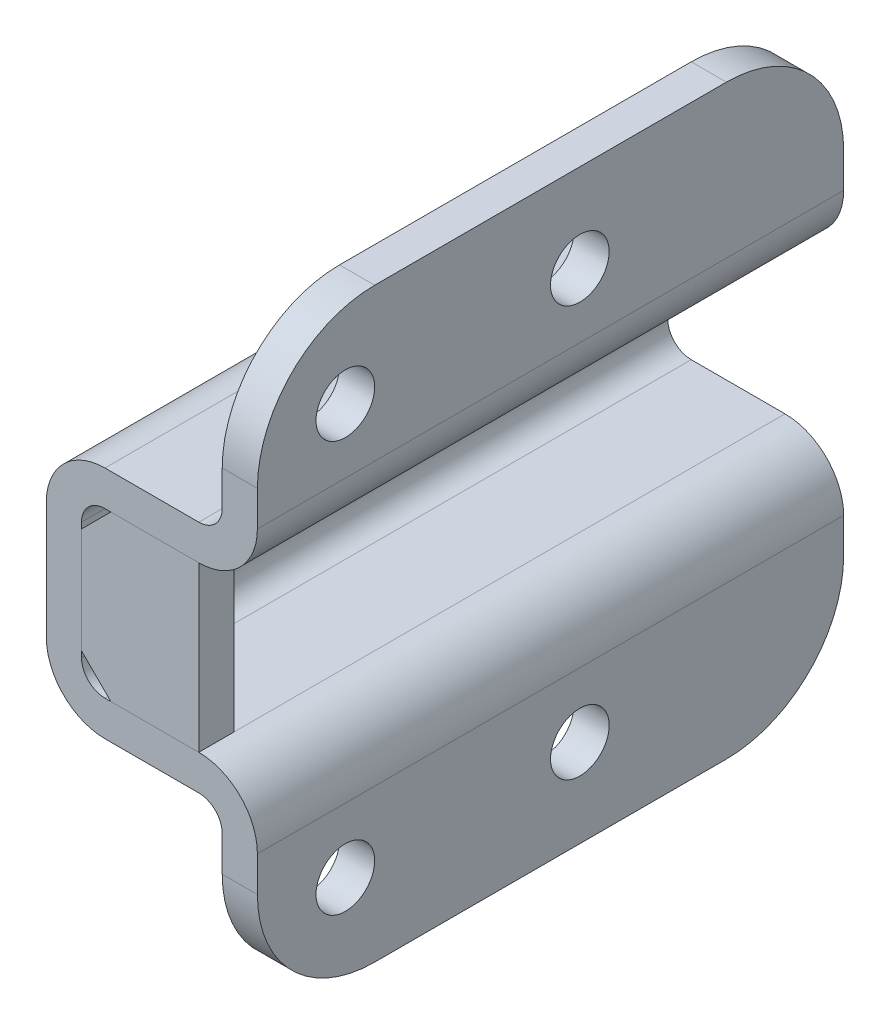
from build123d import *

# Parameters (mm, degrees)
EXTRUDE_1_DEPTH     = 100
CUT_EXTRUDE_1_REACH = 38
SKETCH_2_R          = 5
CUT_EXTRUDE_2_REACH = 8
SKETCH_3_R          = 5
EXTRUDE_2_DEPTH     = 6
FILLET_1_R          = 20


with BuildPart() as part:
    # 草图1 → 凸台-拉伸1 (new body)
    with BuildSketch(Plane.XY):
        with BuildLine():
            Line((0, 10), (0, 30))
            ThreePointArc((0, 30), (2.928932188, 37.071067812), (10, 40))
            Line((10, 40), (26, 40))
            ThreePointArc((26, 40), (28.828427125, 41.171572875), (30, 44))
            Line((30, 44), (30, 70))
            Line((30, 70), (36, 70))
            Line((36, 70), (36, 44))
            ThreePointArc((36, 44), (33.071067812, 36.928932188), (26, 34))
            Line((26, 34), (10, 34))
            ThreePointArc((10, 34), (7.171572875, 32.828427125), (6, 30))
            Line((6, 30), (6, 10))
            ThreePointArc((6, 10), (7.171572875, 7.171572875), (10, 6))
            Line((10, 6), (26, 6))
            ThreePointArc((26, 6), (33.071067812, 3.071067812), (36, -4))
            Line((36, -4), (36, -30))
            Line((36, -30), (30, -30))
            Line((30, -30), (30, -4))
            ThreePointArc((30, -4), (28.828427125, -1.171572875), (26, 0))
            Line((26, 0), (10, 0))
            ThreePointArc((10, 0), (2.928932188, 2.928932188), (0, 10))
        make_face()
    extrude(amount=EXTRUDE_1_DEPTH)

    # 草图2 → 切除-拉伸1 (cut, up to next)
    with BuildSketch(Plane.ZY, mode=Mode.PRIVATE) as cut_extrude_1_sk1:
        with Locations((20, 20)):
            Circle(SKETCH_2_R)
    cut_extrude_1_tool1 = extrude(cut_extrude_1_sk1.sketch, amount=-CUT_EXTRUDE_1_REACH, mode=Mode.PRIVATE) & part.part
    add(cut_extrude_1_tool1.solids().sort_by_distance((0, 20, 20))[0], mode=Mode.SUBTRACT)

    # 草图3 → 切除-拉伸2 (cut, up to next)
    with BuildSketch(Plane.ZY.offset(-30), mode=Mode.PRIVATE) as cut_extrude_2_sk1:
        with Locations((85, 55)):
            Circle(SKETCH_3_R)
    cut_extrude_2_tool1 = extrude(cut_extrude_2_sk1.sketch, amount=-CUT_EXTRUDE_2_REACH, mode=Mode.PRIVATE) & part.part
    add(cut_extrude_2_tool1.solids().sort_by_distance((30, 55, 85))[0], mode=Mode.SUBTRACT)
    # 草图3 → 切除-拉伸2 (cut, up to next)
    with BuildSketch(Plane.ZY.offset(-30), mode=Mode.PRIVATE) as cut_extrude_2_sk2:
        with Locations((45, 55)):
            Circle(SKETCH_3_R)
    cut_extrude_2_tool2 = extrude(cut_extrude_2_sk2.sketch, amount=-CUT_EXTRUDE_2_REACH, mode=Mode.PRIVATE) & part.part
    add(cut_extrude_2_tool2.solids().sort_by_distance((30, 55, 45))[0], mode=Mode.SUBTRACT)
    # 草图3 → 切除-拉伸2 (cut, up to next)
    with BuildSketch(Plane.ZY.offset(-30), mode=Mode.PRIVATE) as cut_extrude_2_sk3:
        with Locations((45, -15)):
            Circle(SKETCH_3_R)
    cut_extrude_2_tool3 = extrude(cut_extrude_2_sk3.sketch, amount=-CUT_EXTRUDE_2_REACH, mode=Mode.PRIVATE) & part.part
    add(cut_extrude_2_tool3.solids().sort_by_distance((30, -15, 45))[0], mode=Mode.SUBTRACT)
    # 草图3 → 切除-拉伸2 (cut, up to next)
    with BuildSketch(Plane.ZY.offset(-30), mode=Mode.PRIVATE) as cut_extrude_2_sk4:
        with Locations((85, -15)):
            Circle(SKETCH_3_R)
    cut_extrude_2_tool4 = extrude(cut_extrude_2_sk4.sketch, amount=-CUT_EXTRUDE_2_REACH, mode=Mode.PRIVATE) & part.part
    add(cut_extrude_2_tool4.solids().sort_by_distance((30, -15, 85))[0], mode=Mode.SUBTRACT)

    # 圆角1
    fillet_1_edges = [part.edges().sort_by_distance(p)[0] for p in [
        (33, -30, 100),
        (33, 70, 0),
        (33, -30, 0),
        (33, 70, 100),
    ]]
    fillet(fillet_1_edges, radius=FILLET_1_R)


with BuildPart() as body_2:
    # 草图4 → 凸台-拉伸2 (new body)
    with BuildSketch(Plane.XY.offset(100)):
        Polygon((11, 34), (26, 34), (26, 6), (11, 6), (6, 11), (6, 29), align=None)
    extrude(amount=-EXTRUDE_2_DEPTH)


solid = Compound([part.part, body_2.part])
